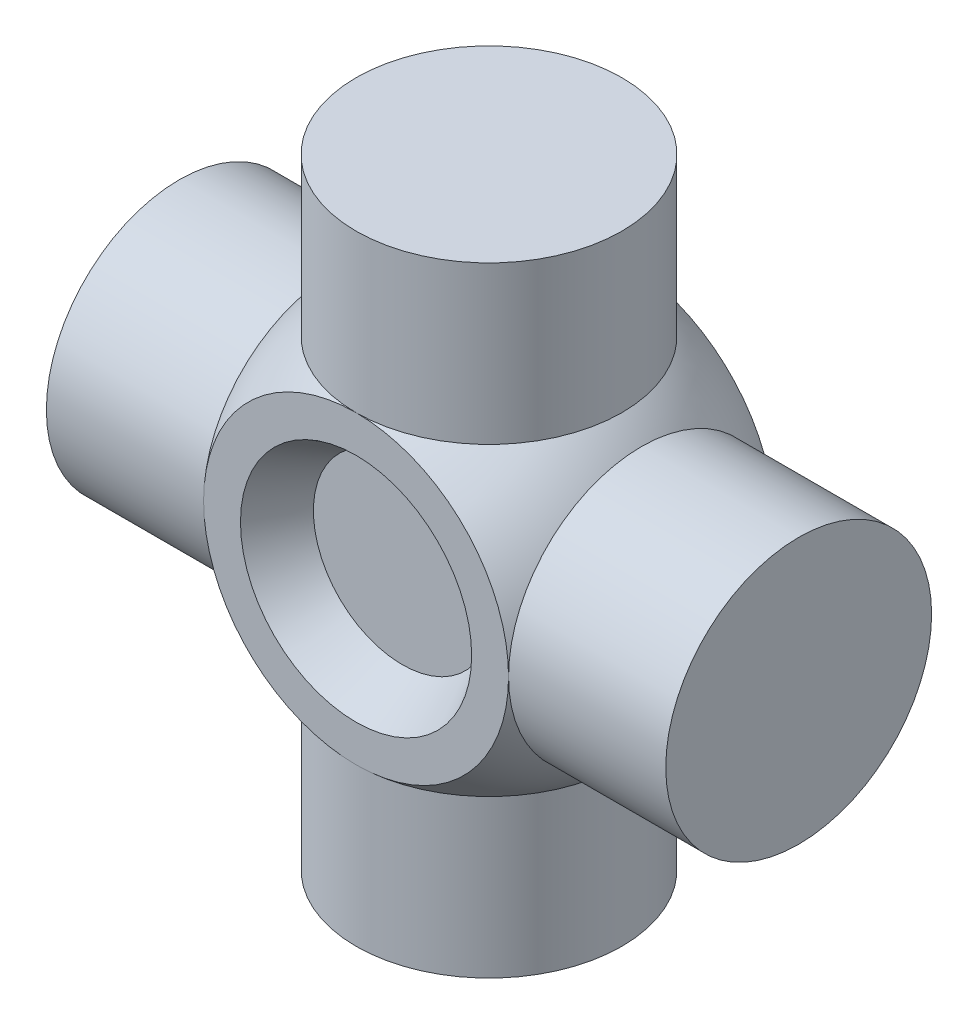
from build123d import *

# Parameters (mm, degrees)
SKETCH2_OUTSIDE_W   = 31.923
SKETCH2_OUTSIDE_H   = 31.922
SKETCH2_OUTSIDE_W_2 = 16.752450568
SKETCH2_OUTSIDE_H_2 = 14.605
CUT_EXTRUDE1_DEPTH  = 10.287
SKETCH3_OUTSIDE_W   = 22.89
SKETCH3_OUTSIDE_H   = 30.51
SKETCH3_OUTSIDE_W_2 = 14.605
SKETCH3_OUTSIDE_H_2 = 16.752450568
CUT_EXTRUDE3_DEPTH  = 11.303
SKETCH6_R           = 6.35
CUT_EXTRUDE4_DEPTH  = 2.54
CUT_EXTRUDE4_TAPER  = 30
BOSS_EXTRUDE1_DEPTH = 8.636
BOSS_EXTRUDE2_DEPTH = 8.636
BOSS_EXTRUDE3_DEPTH = 8.636
BOSS_EXTRUDE4_DEPTH = 8.636


with BuildPart() as part:
    # Sketch1 → Revolve1 (revolve)
    with BuildSketch(Plane(origin=(0, 0, 0), x_dir=(1, 0, 0), z_dir=(0, 1, 0))):
        with BuildLine():
            Line((0, 11.1125), (0, -11.1125))
            ThreePointArc((0, -11.1125), (11.1125, 0), (0, 11.1125))
        make_face()
    revolve(axis=Axis((0, 0, 7.836824486), (0, 0, -1)))

    # Sketch2 outside → Cut-Extrude1 (cut, symmetric)
    with BuildSketch(Plane(origin=(0, 0, 0), x_dir=(1, 0, 0), z_dir=(0, 1, 0))):
        with Locations((-0.0005, 0)):
            Rectangle(SKETCH2_OUTSIDE_W, SKETCH2_OUTSIDE_H)
        Rectangle(SKETCH2_OUTSIDE_W_2, SKETCH2_OUTSIDE_H_2, mode=Mode.SUBTRACT)
    extrude(amount=CUT_EXTRUDE1_DEPTH, both=True, mode=Mode.SUBTRACT)

    # Sketch3 outside → Cut-Extrude3 (cut, symmetric)
    with BuildSketch(Plane(origin=(0, 0, 0), x_dir=(0, 0, -1), z_dir=(1, 0, 0))):
        Rectangle(SKETCH3_OUTSIDE_W, SKETCH3_OUTSIDE_H)
        Rectangle(SKETCH3_OUTSIDE_W_2, SKETCH3_OUTSIDE_H_2, mode=Mode.SUBTRACT)
    extrude(amount=CUT_EXTRUDE3_DEPTH, both=True, mode=Mode.SUBTRACT)

    # Sketch6 → Cut-Extrude4 (cut)
    with BuildSketch(Plane.XY.offset(7.3025)):
        Circle(SKETCH6_R)
    cut_extrude4 = extrude(amount=-CUT_EXTRUDE4_DEPTH, taper=CUT_EXTRUDE4_TAPER, mode=Mode.SUBTRACT)

    # Mirror1: Cut-Extrude4 across plane
    add(cut_extrude4.mirror(Plane.XY), mode=Mode.SUBTRACT)

    # Sketch7 → Boss-Extrude1 (add)
    with BuildSketch(Plane(origin=(8.376225284, 0, 0), x_dir=(0, 0, -1), z_dir=(1, 0, 0))):
        with BuildLine():
            ThreePointArc((7.3025, 0), (0, 7.3025), (-7.3025, 0))
            ThreePointArc((-7.3025, 0), (0, -7.3025), (7.3025, 0))
        make_face()
    extrude(amount=BOSS_EXTRUDE1_DEPTH)

    # Sketch11 → Boss-Extrude2 (add)
    with BuildSketch(Plane(origin=(0, 8.376225284, 0), x_dir=(1, 0, 0), z_dir=(0, 1, 0))):
        with BuildLine():
            ThreePointArc((0, -7.3025), (7.3025, 0), (0, 7.3025))
            ThreePointArc((0, 7.3025), (-7.3025, 0), (0, -7.3025))
        make_face()
    extrude(amount=BOSS_EXTRUDE2_DEPTH)

    # Sketch12 → Boss-Extrude3 (add)
    with BuildSketch(Plane.ZY.offset(8.376225284)):
        with BuildLine():
            ThreePointArc((7.3025, 0), (0, 7.3025), (-7.3025, 0))
            ThreePointArc((-7.3025, 0), (0, -7.3025), (7.3025, 0))
        make_face()
    extrude(amount=BOSS_EXTRUDE3_DEPTH)

    # Sketch13 → Boss-Extrude4 (add)
    with BuildSketch(Plane.XZ.offset(8.376225284)):
        with BuildLine():
            ThreePointArc((0, -7.3025), (7.3025, 0), (0, 7.3025))
            ThreePointArc((0, 7.3025), (-7.3025, 0), (0, -7.3025))
        make_face()
    extrude(amount=BOSS_EXTRUDE4_DEPTH)


solid = part.part
